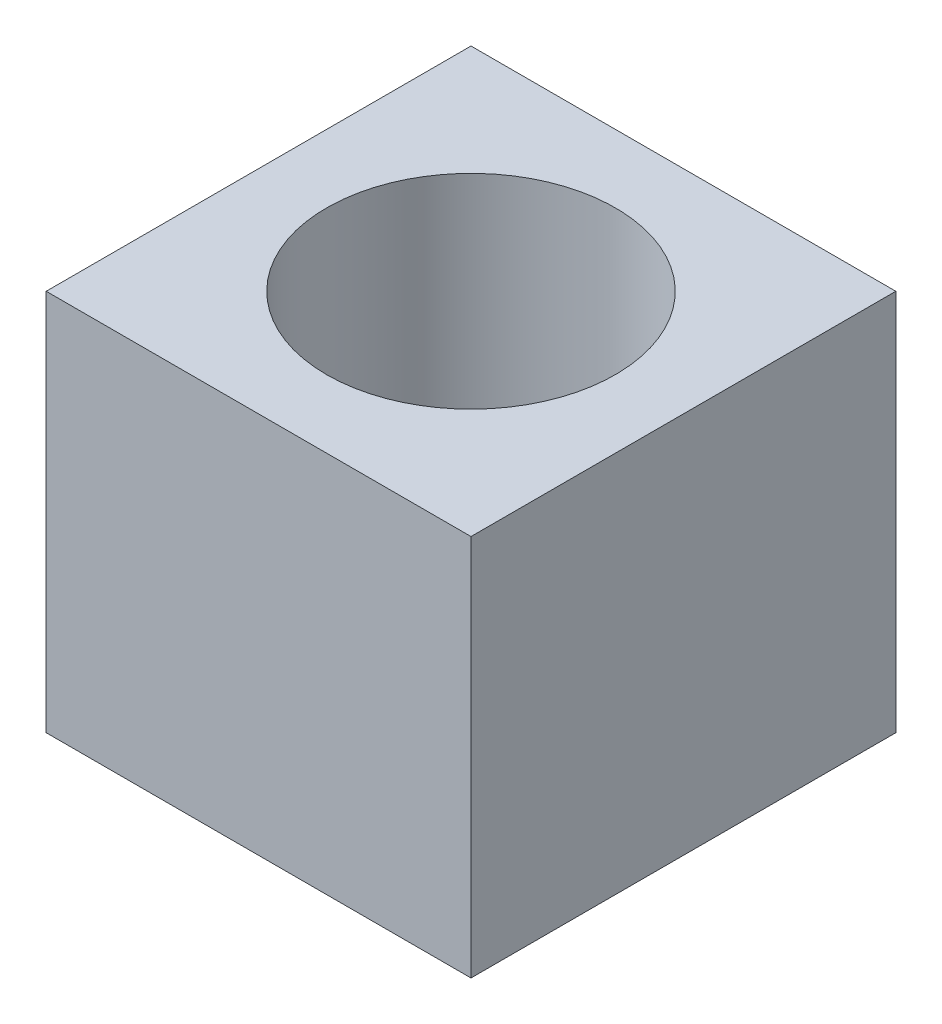
from build123d import *

# Parameters (mm, degrees)
SKETCH1_W           = 5
SKETCH1_H           = 5
SKETCH1_R           = 1.7
BOSS_EXTRUDE1_DEPTH = 4.5


with BuildPart() as part:
    # Sketch1 → Boss-Extrude1 (new body)
    with BuildSketch(Plane(origin=(0, 0, 0), x_dir=(1, 0, 0), z_dir=(0, 1, 0))):
        Rectangle(SKETCH1_W, SKETCH1_H)
        Circle(SKETCH1_R, mode=Mode.SUBTRACT)
    extrude(amount=BOSS_EXTRUDE1_DEPTH)


solid = part.part
